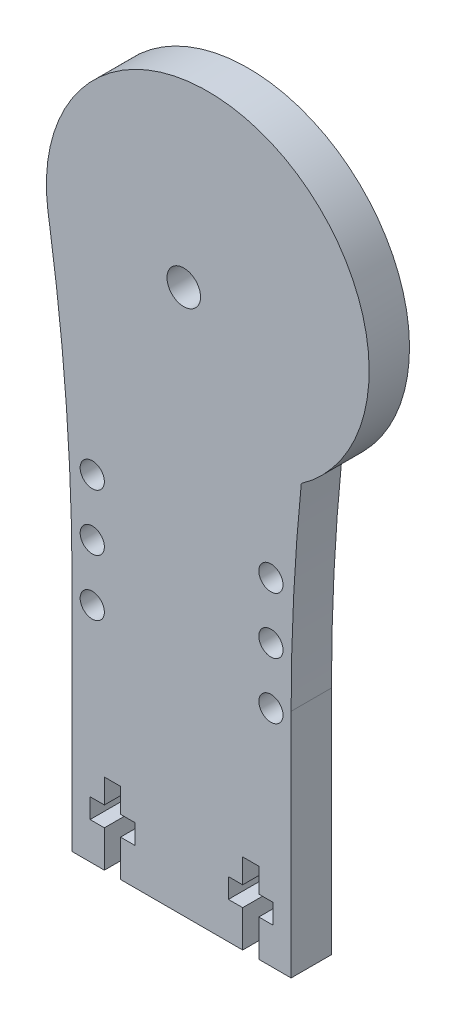
from build123d import *

# Parameters (mm, degrees)
RESSALTO_EXTRUS_O1_DEPTH = 5
ESBO_O7_R                = 2.076684074
CORTE_EXTRUS_O5_DEPTH    = 6
ESBO_O8_W                = 32.941442616
ESBO_O8_H                = 7.70353162
CORTE_EXTRUS_O6_DEPTH    = 6
ESBO_O9_R                = 1.5
CORTE_EXTRUS_O7_DEPTH    = 6
ESBO_O10_W               = 2
ESBO_O10_H               = 3
CORTE_EXTRUS_O8_DEPTH    = 6


with BuildPart() as part:
    # Esboço1 → Ressalto-extrusão1 (new body)
    with BuildSketch(Plane.XY):
        with BuildLine():
            Line((13.569146061, 27.715579822), (13.569146061, 56.338894978))
            ThreePointArc((13.569146061, 56.338894978), (13.884544414, 68.892766914), (14.829943665, 81.414963086))
            ThreePointArc((14.829943665, 81.414963086), (11.193742071, 116.066691762), (-16.576524471, 95.024435265))
            Line((-16.576524471, 95.024435265), (-16.487894969, 94.437265709))
            Line((-16.487894969, 94.437265709), (-16.369382775, 93.652123615))
            ThreePointArc((-16.369382775, 93.652123615), (-14.270188159, 75.047972701), (-13.569146061, 56.338894978))
            Line((-13.569146061, 56.338894978), (-13.569146061, 27.715579822))
            ThreePointArc((-13.569146061, 27.715579822), (0, 21.02683783), (13.569146061, 27.715579822))
        make_face()
    extrude(amount=RESSALTO_EXTRUS_O1_DEPTH)

    # Esboço7 → Corte-extrusão5 (cut, through all)
    with BuildSketch(Plane(origin=(0, 0, 0), x_dir=(-1, 0, 0), z_dir=(0, 0, -1))):
        with Locations((-0.267564972, 95.19)):
            Circle(ESBO_O7_R)
    extrude(amount=-CORTE_EXTRUS_O5_DEPTH, mode=Mode.SUBTRACT)

    # Esboço8 → Corte-extrusão6 (cut, through all)
    with BuildSketch(Plane.XY.offset(5)):
        with Locations((-2.901575247, 23.863814012)):
            Rectangle(ESBO_O8_W, ESBO_O8_H)
    extrude(amount=-CORTE_EXTRUS_O6_DEPTH, mode=Mode.SUBTRACT)

    # Esboço9 → Corte-extrusão7 (cut, through all)
    with BuildSketch(Plane(origin=(0, 0, 0), x_dir=(-1, 0, 0), z_dir=(0, 0, -1))):
        with Locations((11.072435028, 69.41)):
            Circle(ESBO_O9_R)
        with Locations((11.072435028, 62.41)):
            Circle(ESBO_O9_R)
        with Locations((11.072435028, 55.41)):
            Circle(ESBO_O9_R)
        with Locations((-11.067564972, 69.41)):
            Circle(ESBO_O9_R)
        with Locations((-11.067564972, 62.41)):
            Circle(ESBO_O9_R)
        with Locations((-11.067564972, 55.41)):
            Circle(ESBO_O9_R)
    extrude(amount=-CORTE_EXTRUS_O7_DEPTH, mode=Mode.SUBTRACT)

    # Esboço10 → Corte-extrusão8 (cut, through all)
    with BuildSketch(Plane(origin=(0, 0, 0), x_dir=(-1, 0, 0), z_dir=(0, 0, -1))):
        Polygon((7.569146061, 27.715579822), (9.569146061, 27.715579822), (9.569146061, 32.265579822), (11.339146061, 32.265579822), (11.339146061, 34.715579822), (9.569146061, 34.715579822), (7.569146061, 34.715579822), (5.799146061, 34.715579822), (5.799146061, 32.265579822), (7.569146061, 32.265579822), align=None)
        with Locations((8.569146061, 36.215579822)):
            Rectangle(ESBO_O10_W, ESBO_O10_H)
        Polygon((-9.569146061, 27.715579822), (-7.569146061, 27.715579822), (-7.569146061, 32.265579822), (-5.799146061, 32.265579822), (-5.799146061, 34.715579822), (-7.569146061, 34.715579822), (-7.569146061, 37.715579822), (-9.569146061, 37.715579822), (-9.569146061, 34.715579822), (-11.339146061, 34.715579822), (-11.339146061, 32.265579822), (-9.569146061, 32.265579822), align=None)
    extrude(amount=-CORTE_EXTRUS_O8_DEPTH, mode=Mode.SUBTRACT)


solid = part.part
